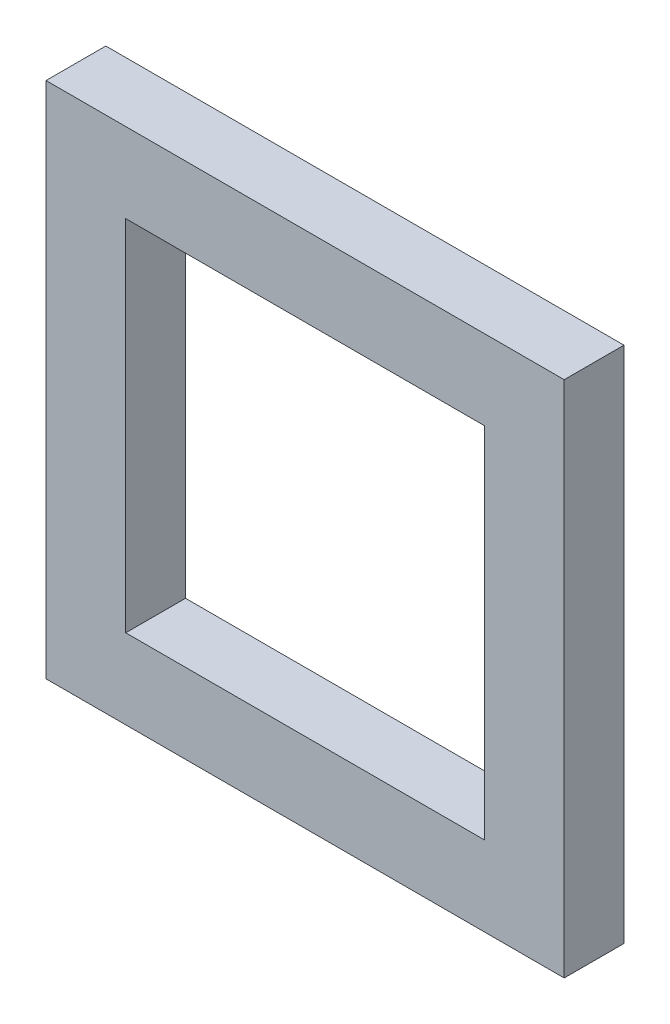
from build123d import *

# Parameters (mm, degrees)
SKETCH1_W           = 13
SKETCH1_H           = 13
SKETCH1_W_2         = 9
SKETCH1_H_2         = 9
BOSS_EXTRUDE1_DEPTH = 1.5


with BuildPart() as part:
    # Sketch1 → Boss-Extrude1 (new body)
    with BuildSketch(Plane.XY):
        Rectangle(SKETCH1_W, SKETCH1_H)
        Rectangle(SKETCH1_W_2, SKETCH1_H_2, mode=Mode.SUBTRACT)
    extrude(amount=BOSS_EXTRUDE1_DEPTH)


solid = part.part
